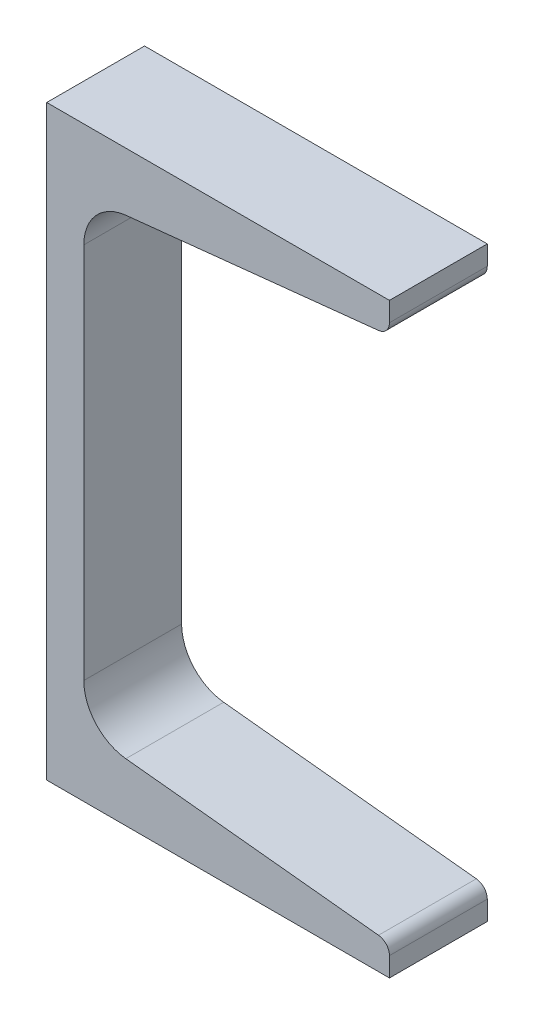
from build123d import *

# Parameters (mm, degrees)
BASEMCHANNEL_DEPTH = 12.7
TOEFILLET_R        = 3.175


with BuildPart() as part:
    # Sketch1 → BaseMchannel (new body, symmetric)
    with BuildSketch(Plane.XY):
        with BuildLine():
            Line((89.0016, 152.4), (0, 152.4))
            Line((0, 152.4), (0, 0))
            Line((0, 0), (89.0016, 0))
            Line((89.0016, 0), (89.0016, 7.893675663))
            Line((89.0016, 7.893675663), (20.544188976, 15.088839497))
            ThreePointArc((20.544188976, 15.088839497), (12.758178288, 19.056010093), (9.6266, 27.214050446))
            Line((9.6266, 27.214050446), (9.6266, 125.185949554))
            ThreePointArc((9.6266, 125.185949554), (12.758178288, 133.343989907), (20.544188976, 137.311160503))
            Line((20.544188976, 137.311160503), (89.0016, 144.506324337))
            Line((89.0016, 144.506324337), (89.0016, 152.4))
        make_face()
    extrude(amount=BASEMCHANNEL_DEPTH, both=True)

    # ToeFillet
    toefillet_edges = [part.edges().sort_by_distance(p)[0] for p in [
        (89.0016, 144.506324337, 0),
        (89.0016, 7.893675663, 0),
    ]]
    fillet(toefillet_edges, radius=TOEFILLET_R)


solid = part.part
